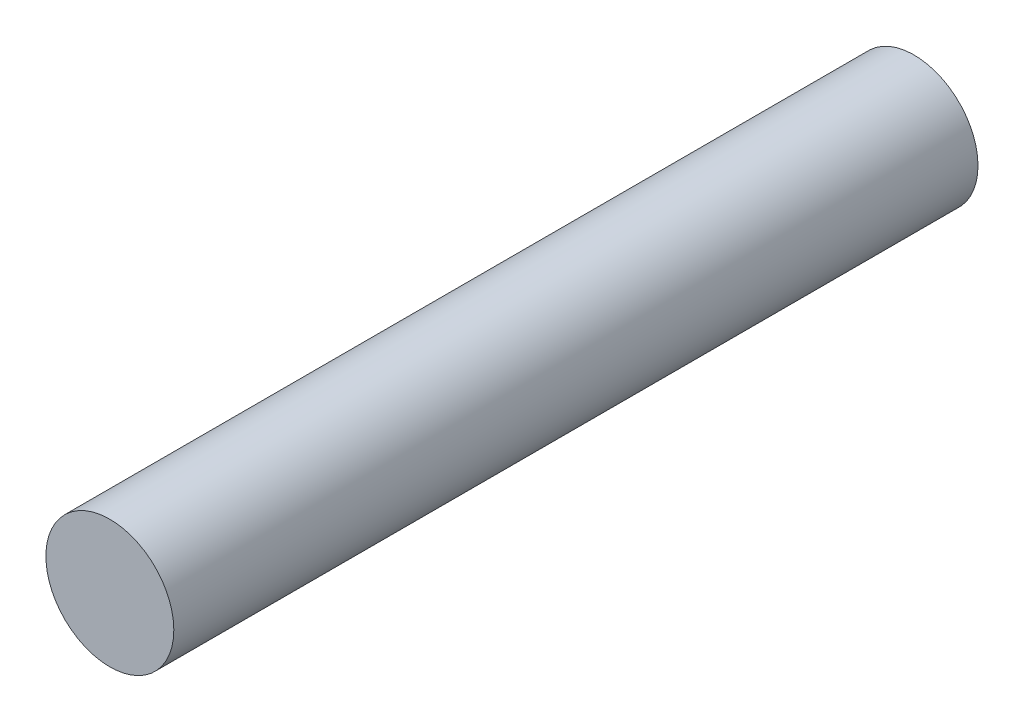
from build123d import *

# Parameters (mm, degrees)
MARKER_BODY_SKETCH_R      = 11.1125
MARKER_BODY_EXTRUDE_DEPTH = 139.7


with BuildPart() as part:
    # Marker Body Sketch → Marker Body Extrude (new body)
    with BuildSketch(Plane.XY):
        Circle(MARKER_BODY_SKETCH_R)
    extrude(amount=MARKER_BODY_EXTRUDE_DEPTH)


solid = part.part
